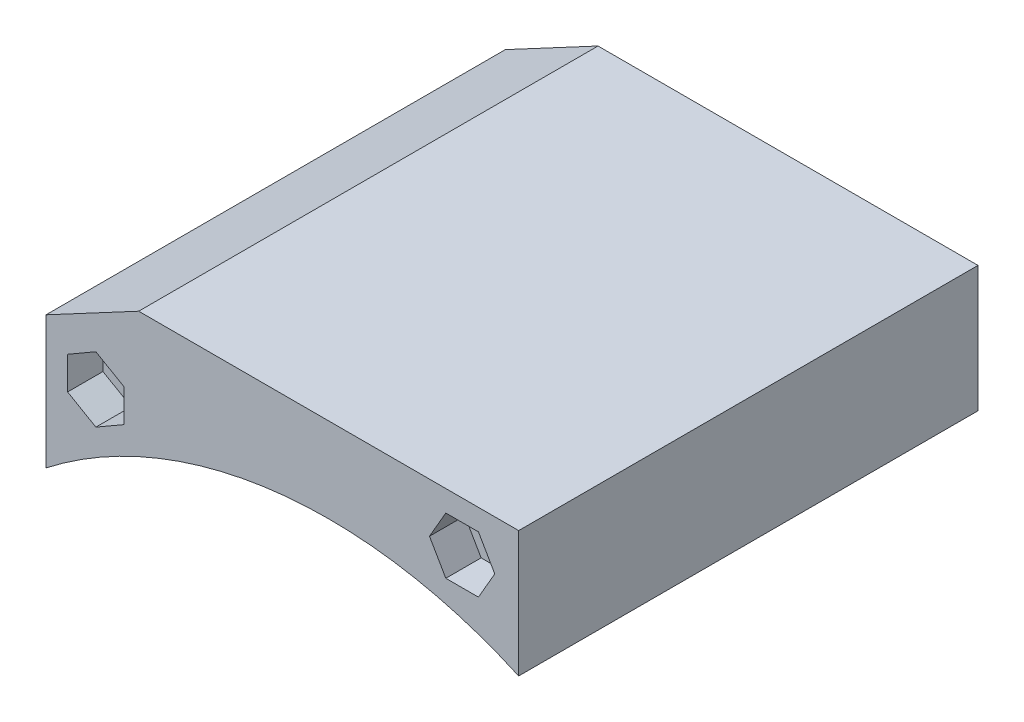
from build123d import *

# Parameters (mm, degrees)
BOSS_EXTRUDE1_DEPTH = 65
CUT_EXTRUDE1_DEPTH  = 5
CUT_EXTRUDE2_DEPTH  = 5
SKETCH4_R           = 2.1
CUT_EXTRUDE3_DEPTH  = 10
SKETCH5_R           = 2.1
CUT_EXTRUDE4_DEPTH  = 10


with BuildPart() as part:
    # Sketch1 → Boss-Extrude1 (new body)
    with BuildSketch(Plane.XY):
        with BuildLine():
            Line((-26.885, 0), (26.885, 0))
            Line((26.885, 0), (26.885, -17.820638944))
            ThreePointArc((26.885, -17.820638944), (-7.666811739, -12.453737538), (-40, -25.76524617))
            Line((-40, -25.76524617), (-40, -7))
            Line((-40, -7), (-26.885, 0))
        make_face()
    extrude(amount=BOSS_EXTRUDE1_DEPTH)

    # Sketch2 → Cut-Extrude1 (cut)
    with BuildSketch(Plane.XY.offset(65)):
        Polygon((-32.94236854, -17.234485077), (-28.94236854, -14.925084), (-28.94236854, -10.306281847), (-32.94236854, -7.99688077), (-36.94236854, -10.306281847), (-36.94236854, -14.925084), align=None)
        Polygon((14.266197846, -7), (16.575598923, -11), (21.194401077, -11), (23.503802154, -7), (21.194401077, -3), (16.575598923, -3), align=None)
    extrude(amount=-CUT_EXTRUDE1_DEPTH, mode=Mode.SUBTRACT)

    # Sketch3 → Cut-Extrude2 (cut)
    with BuildSketch(Plane(origin=(0, 0, 0), x_dir=(-1, 0, 0), z_dir=(0, 0, -1))):
        Polygon((28.861855536, -10.451717361), (29.028062888, -15.067528064), (33.108575892, -17.231493627), (37.022881544, -14.779648487), (36.856674193, -10.163837783), (32.776161189, -7.99987222), align=None)
        Polygon((-16.5261006, -10.971010823), (-14.266554049, -6.942638606), (-16.625453449, -2.971627783), (-21.2438994, -3.028989177), (-23.503445951, -7.057361394), (-21.144546551, -11.028372217), align=None)
    extrude(amount=-CUT_EXTRUDE2_DEPTH, mode=Mode.SUBTRACT)

    # Sketch4 → Cut-Extrude3 (cut)
    with BuildSketch(Plane(origin=(0, 0, 5), x_dir=(-1, 0, 0), z_dir=(0, 0, -1))):
        with Locations((32.94236854, -12.615682924)):
            Circle(SKETCH4_R)
        with Locations((-18.885, -7)):
            Circle(SKETCH4_R)
    extrude(amount=-CUT_EXTRUDE3_DEPTH, mode=Mode.SUBTRACT)

    # Sketch5 → Cut-Extrude4 (cut)
    with BuildSketch(Plane.XY.offset(60)):
        with Locations((-32.94236854, -12.615682924)):
            Circle(SKETCH5_R)
        with Locations((18.885, -7)):
            Circle(SKETCH5_R)
    extrude(amount=-CUT_EXTRUDE4_DEPTH, mode=Mode.SUBTRACT)


solid = part.part
